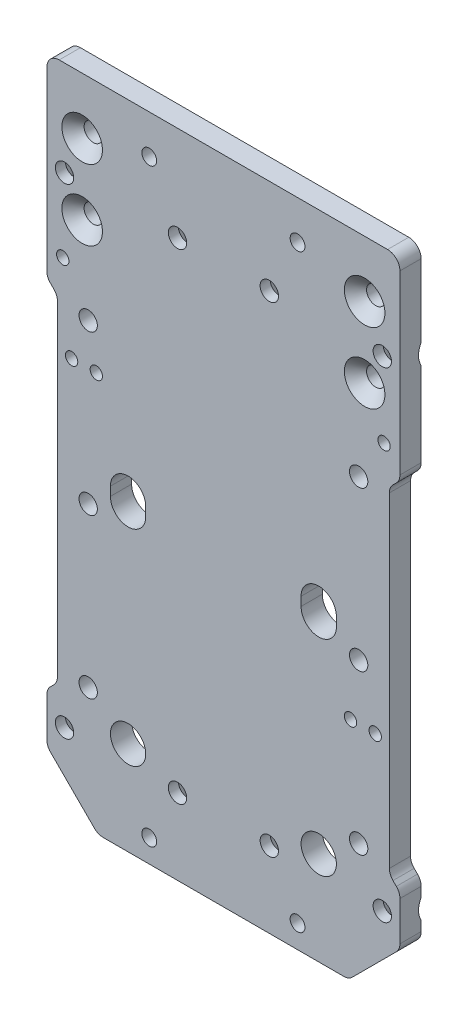
from build123d import *

# Parameters (mm, degrees)
SKETCH1_W                                  = 100
SKETCH1_H                                  = 170
BODY_DEPTH                                 = 3
REDUCESOMEWIDTH_DEPTH                      = 7
SCREWHEADHOLECARRIAGEY_R                   = 5
CUTFOROTHERSCREWSHEADS_DEPTH               = 7
ENDMILLMINIMUMRADIUS_R                     = 3.5
F_3_5_3_5_CABLETIEHOLES_D                  = 3.5
F_4_2_4_2_KP8_HOLES1_D                     = 4.2
F_4_2_4_2_KP8_HOLES2_D                     = 4.2
F_5_2_5_2_MOUNTANGLECORNERHOLES_AT_2_COUNT = 2
F_5_2_5_2_MOUNTANGLECORNERHOLES_AT_2_PITCH = 20
F_5_2_5_2_MOUNTANGLECORNERHOLES_AT_3_COUNT = 2
F_5_2_5_2_MOUNTANGLECORNERHOLES_AT_3_PITCH = 80
F_5_2_5_2_MOUNTANGLECORNERHOLES_AT_4_COUNT = 2
F_5_2_5_2_MOUNTANGLECORNERHOLES_AT_4_PITCH = 82.462112512
F_5_2_5_2_SK8_MOUNT_HOLES_D                = 5.2
F_5_2_5_2_SK8_MOUNT_HOLES_CSINK_D          = 11.5
F_5_2_5_2_SK8_MOUNT_HOLES_CSINK_ANGLE      = 90
F_3_5_3_5_ENDSENSORSHOLES_D                = 3.5
F_3_5_3_5_ENDSENSORSHOLES_CSINK_D          = 6.5
F_3_5_3_5_ENDSENSORSHOLES_CSINK_ANGLE      = 90
F_5_2_5_2_MOUNTTOBASEHOLES_D               = 5.2


with BuildPart() as part:
    # Sketch1 → Body (new body, symmetric)
    with BuildSketch(Plane.XY):
        Polygon((50, 0), (-50, 0), (-35.5, -14.5), (35.5, -14.5), align=None)
        with Locations((0, 85)):
            Rectangle(SKETCH1_W, SKETCH1_H)
    extrude(amount=BODY_DEPTH, both=True)

    # Sketch6 → ReduceSomeWidth (cut, through all)
    with BuildSketch(Plane.XY.offset(3)):
        Polygon((-50, 115), (-47, 112), (-47, 17), (-50, 14), align=None)
        Polygon((50, 115), (47, 112), (47, 17), (50, 14), align=None)
    extrude(amount=-REDUCESOMEWIDTH_DEPTH, mode=Mode.SUBTRACT)

    # screwHeadHoleCarriageY → CutForOtherScrewsHeads (cut, through all)
    with BuildSketch(Plane(origin=(0, 0, -3), x_dir=(-1, 0, 0), z_dir=(0, 0, -1))):
        with Locations((-27, 12)):
            Circle(SCREWHEADHOLECARRIAGEY_R)
        with Locations((27, 12)):
            Circle(SCREWHEADHOLECARRIAGEY_R)
        with BuildLine():
            Line((-32, 70.2), (-32, 72.7))
            ThreePointArc((-32, 72.7), (-27, 77.7), (-22, 72.7))
            Line((-22, 72.7), (-22, 70.2))
            ThreePointArc((-22, 70.2), (-27, 65.2), (-32, 70.2))
        make_face()
        with BuildLine():
            Line((22, 70.2), (22, 72.7))
            ThreePointArc((22, 72.7), (27, 77.7), (32, 72.7))
            Line((32, 72.7), (32, 70.2))
            ThreePointArc((32, 70.2), (27, 65.2), (22, 70.2))
        make_face()
    extrude(amount=-CUTFOROTHERSCREWSHEADS_DEPTH, mode=Mode.SUBTRACT)

    # EndMillMinimumRadius
    endmillminimumradius_edges = [part.edges().sort_by_distance(p)[0] for p in [
        (50, 170, 0),
        (50, 0, 0),
        (35.5, -14.5, 0),
        (-35.5, -14.5, 0),
        (-50, 0, 0),
        (-50, 170, 0),
        (-50, 14, 0),
        (-50, 115, 0),
        (-47, 112, 0),
        (-47, 17, 0),
        (50, 115, 0),
        (50, 14, 0),
        (47, 17, 0),
        (47, 112, 0),
    ]]
    fillet(endmillminimumradius_edges, radius=ENDMILLMINIMUMRADIUS_R)

    # Ø3.5 (3.5) CableTieHoles (through all)
    with Locations(Plane(origin=(0, 0, -3), x_dir=(-1, 0, 0), z_dir=(0, 0, -1))):
        with Locations((-45.5, 122), (45.5, 122)):
            Hole(F_3_5_3_5_CABLETIEHOLES_D / 2)

    # Ø4.2 (4.2) KP8 Holes1 (through all)
    with Locations(Plane(origin=(0, 0, -3), x_dir=(-1, 0, 0), z_dir=(0, 0, -1))):
        with Locations((-21, 159), (21, 159)):
            Hole(F_4_2_4_2_KP8_HOLES1_D / 2)

    # Ø4.2 (4.2) KP8 Holes2 (through all)
    with Locations(Plane(origin=(0, 0, -3), x_dir=(-1, 0, 0), z_dir=(0, 0, -1))):
        with Locations((-21, -8), (21, -8)):
            Hole(F_4_2_4_2_KP8_HOLES2_D / 2)

    # Sketch16 → Ø5.2 (5.2) MountAngleCornerHoles (revolve, cut)
    with BuildSketch(Plane(origin=(40, 154, -3), x_dir=(0, 1, 0), z_dir=(1, 0, 0))):
        Polygon((0, 0), (0, 6), (5.75, 6), (2.6, 2.85), (2.6, 0), align=None)
    f_5_2_5_2_mountanglecornerholes = revolve(axis=Axis((40, 154, -9.35), (0, 0, 1)), mode=Mode.SUBTRACT)

    # Ø5.2 (5.2) MountAngleCornerHoles at 2: Ø5.2 (5.2) MountAngleCornerHoles ×2
    with Locations(*[(0, -i * F_5_2_5_2_MOUNTANGLECORNERHOLES_AT_2_PITCH, 0) for i in range(1, F_5_2_5_2_MOUNTANGLECORNERHOLES_AT_2_COUNT)]):
        add(f_5_2_5_2_mountanglecornerholes, mode=Mode.SUBTRACT)

    # Ø5.2 (5.2) MountAngleCornerHoles at 3: Ø5.2 (5.2) MountAngleCornerHoles ×2
    with Locations(*[(-i * F_5_2_5_2_MOUNTANGLECORNERHOLES_AT_3_PITCH, 0, 0) for i in range(1, F_5_2_5_2_MOUNTANGLECORNERHOLES_AT_3_COUNT)]):
        add(f_5_2_5_2_mountanglecornerholes, mode=Mode.SUBTRACT)

    # Ø5.2 (5.2) MountAngleCornerHoles at 4: Ø5.2 (5.2) MountAngleCornerHoles ×2
    with Locations(*[Vector(-0.9701425, -0.242535625, 0) * (i * F_5_2_5_2_MOUNTANGLECORNERHOLES_AT_4_PITCH) for i in range(1, F_5_2_5_2_MOUNTANGLECORNERHOLES_AT_4_COUNT)]):
        add(f_5_2_5_2_mountanglecornerholes, mode=Mode.SUBTRACT)

    # Ø5.2 (5.2) SK8 Mount Holes (through all)
    with Locations(Plane(origin=(0, 0, -3), x_dir=(-1, 0, 0), z_dir=(0, 0, -1))):
        with Locations((-45, 143.1), (-13, 143.1), (13, 143.1), (45, 143.1), (-45, 7), (-13, 7), (13, 7), (45, 7)):
            CounterSinkHole(F_5_2_5_2_SK8_MOUNT_HOLES_D / 2, F_5_2_5_2_SK8_MOUNT_HOLES_CSINK_D / 2, counter_sink_angle=F_5_2_5_2_SK8_MOUNT_HOLES_CSINK_ANGLE)

    # Ø3.5 (3.5) EndSensorsHoles (through all)
    with Locations(Plane(origin=(0, 0, -3), x_dir=(-1, 0, 0), z_dir=(0, 0, -1))):
        with Locations((-43, 49.5), (-36, 49.5), (36, 98.5), (43, 98.5)):
            CounterSinkHole(F_3_5_3_5_ENDSENSORSHOLES_D / 2, F_3_5_3_5_ENDSENSORSHOLES_CSINK_D / 2, counter_sink_angle=F_3_5_3_5_ENDSENSORSHOLES_CSINK_ANGLE)

    # Ø5.2 (5.2) MountToBaseHoles (through all)
    with Locations(Plane.XY.offset(3)):
        with Locations((-38.3, 110.2), (-38.3, 65.2), (-38.3, 20.2), (38.3, 20.2), (38.3, 65.2), (38.3, 110.2)):
            Hole(F_5_2_5_2_MOUNTTOBASEHOLES_D / 2)


solid = part.part
